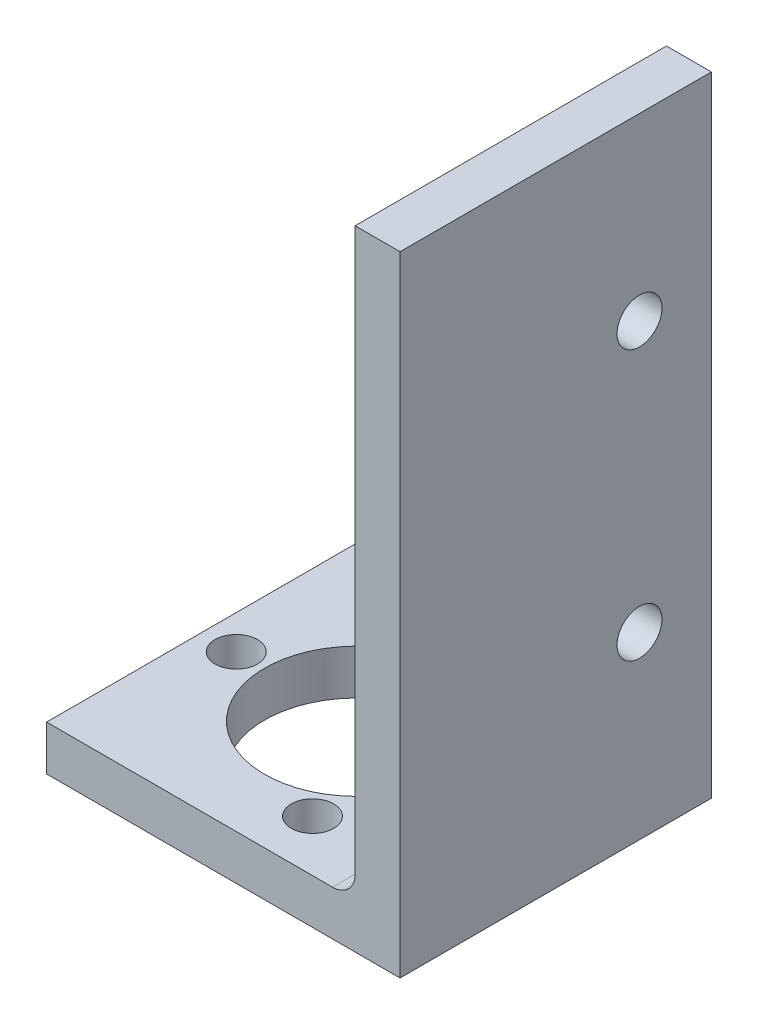
from build123d import *

# Parameters (mm, degrees)
BOSS_EXTRUDE1_DEPTH = 11
FILLET1_R           = 1.5875
SKETCH3_W           = 24.423912887
SKETCH3_H           = 26.552361768
CUT_EXTRUDE1_DEPTH  = 61.908127536
SKETCH4_R           = 1.5
SKETCH4_R_2         = 6.5
SKETCH4_W           = 25.825
SKETCH4_H           = 22
CUT_EXTRUDE2_DEPTH  = 53.363751775
SKETCH5_R           = 1.5875
CUT_EXTRUDE3_DEPTH  = 53.158921816


with BuildPart() as part:
    # Sketch2 → Boss-Extrude1 (new, symmetric)
    with BuildSketch(Plane.XY):
        Polygon((-25.4, 0), (25.4, 0), (25.4, 50.8), (22.225, 50.8), (22.225, 3.175), (-25.4, 3.175), align=None)
    extrude(amount=BOSS_EXTRUDE1_DEPTH, both=True)

    # Fillet1
    fillet1_edges = [part.edges().sort_by_distance(p)[0] for p in [
        (22.225, 3.175, 0),
    ]]
    fillet(fillet1_edges, radius=FILLET1_R)

    # Sketch3 → Cut-Extrude1 (cut, through all)
    with BuildSketch(Plane.XY.offset(11)):
        with Locations((18.271034128, 57.726180884)):
            Rectangle(SKETCH3_W, SKETCH3_H)
    extrude(amount=-CUT_EXTRUDE1_DEPTH, mode=Mode.SUBTRACT)

    # Sketch4 → Cut-Extrude2 (cut, through all)
    with BuildSketch(Plane.XZ):
        with Locations(Location((15.575, -7.361215932, 0), (0, 0, 270))):
            Circle(SKETCH4_R)
        with Locations(Location((11.325, 0, 0), (0, 0, 270))):
            Circle(SKETCH4_R_2)
        with Locations(Location((15.575, 7.361215932, 0), (0, 0, 270))):
            Circle(SKETCH4_R)
        with Locations((-12.4875, 0)):
            Rectangle(SKETCH4_W, SKETCH4_H)
        with Locations(Location((2.825, 0, 0), (0, 0, 270))):
            Circle(SKETCH4_R)
    extrude(amount=-CUT_EXTRUDE2_DEPTH, mode=Mode.SUBTRACT)

    # Sketch5 → Cut-Extrude3 (cut, through all)
    with BuildSketch(Plane(origin=(25.4, 0, 0), x_dir=(0, 0, -1), z_dir=(1, 0, 0))):
        with Locations((5.92, 31.75)):
            Circle(SKETCH5_R)
        with Locations((5.92, 12.7)):
            Circle(SKETCH5_R)
    extrude(amount=-CUT_EXTRUDE3_DEPTH, mode=Mode.SUBTRACT)


solid = part.part
